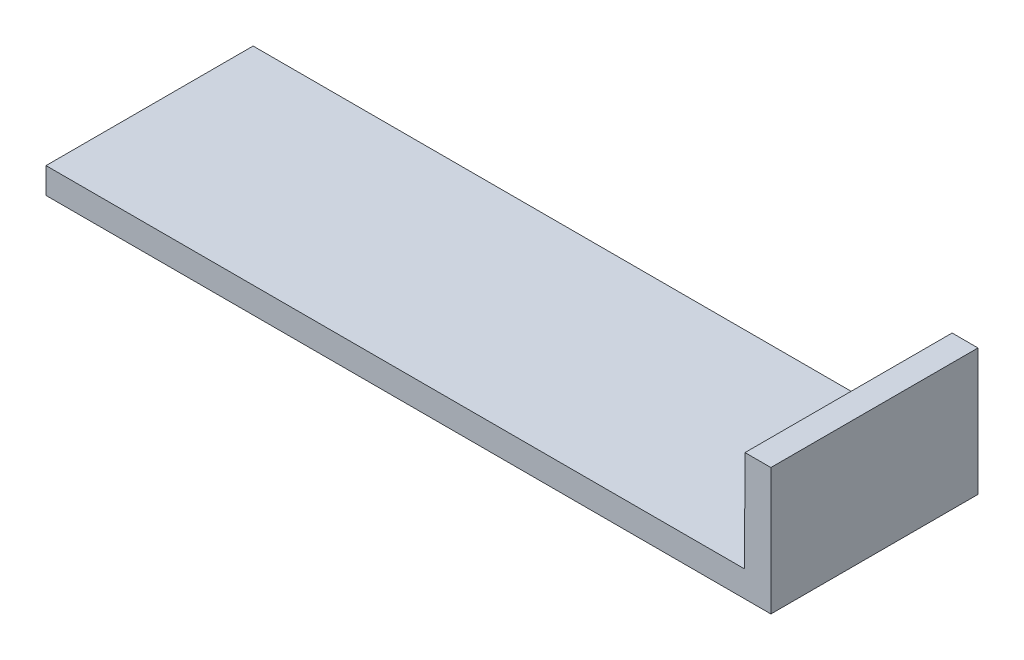
from build123d import *

# Parameters (mm, degrees)
BOSS_EXTRUDE1_DEPTH = 25.4


with BuildPart() as part:
    # Sketch1 → Boss-Extrude1 (new body)
    with BuildSketch(Plane.XY):
        Polygon((0, 0), (-88.9, 0), (-88.9, 3.175), (-3.2385, 3.175), (-3.175, 15.5575), (0, 15.5575), align=None)
    extrude(amount=BOSS_EXTRUDE1_DEPTH)


solid = part.part
